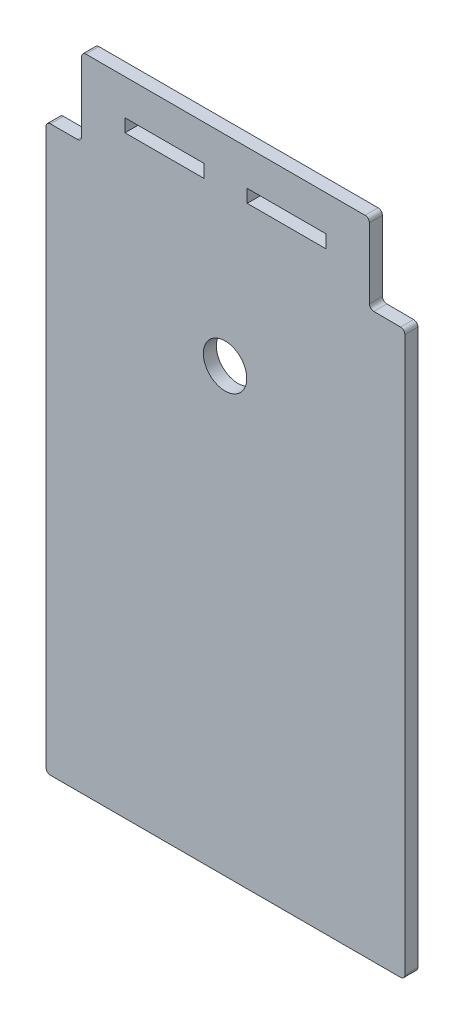
from build123d import *

# Parameters (mm, degrees)
MODEL_R                 = 5
MODEL_W                 = 18.163611367
MODEL_H                 = 3
MODEL_W_2               = 18.163611368
SALIENTE_EXTRUIR1_DEPTH = 3


with BuildPart() as part:
    # Model → Saliente-Extruir1 (new body)
    with BuildSketch(Plane.XY):
        with BuildLine():
            Line((95.99768192, -24.017865973), (95.99768192, 103.764725177))
            ThreePointArc((95.99768192, 103.764725177), (95.708514347, 104.473363697), (95.002958892, 104.769974448))
            Line((95.002958892, 104.769974448), (88.830267122, 104.802462525))
            ThreePointArc((88.830267122, 104.802462525), (88.124711667, 105.099073276), (87.835544094, 105.807711796))
            Line((87.835544094, 105.807711796), (87.824904655, 121.982134027))
            ThreePointArc((87.824904655, 121.982134027), (87.532011436, 122.689240808), (86.824904655, 122.982134027))
            Line((86.824904655, 122.982134027), (22.49768192, 122.982134027))
            ThreePointArc((22.49768192, 122.982134027), (21.790575139, 122.689240808), (21.49768192, 121.982134027))
            Line((21.49768192, 121.982134027), (21.49768192, 105.982134027))
            ThreePointArc((21.49768192, 105.982134027), (21.204788701, 105.275027246), (20.49768192, 104.982134027))
            Line((20.49768192, 104.982134027), (14.324904655, 104.982134027))
            ThreePointArc((14.324904655, 104.982134027), (13.617797874, 104.689240808), (13.324904655, 103.982134027))
            Line((13.324904655, 103.982134027), (13.324904655, 59.982134027))
            Line((13.324904655, 59.982134027), (13.324904655, 53.982134027))
            Line((13.324904655, 53.982134027), (13.324904655, 21.297944303))
            Line((13.324904655, 21.297944303), (13.324904655, -24.017865973))
            ThreePointArc((13.324904655, -24.017865973), (13.617797874, -24.724972754), (14.324904655, -25.017865973))
            Line((14.324904655, -25.017865973), (94.99768192, -25.017865973))
            ThreePointArc((94.99768192, -25.017865973), (95.704788701, -24.724972754), (95.99768192, -24.017865973))
        make_face()
        with Locations((54.561293288, 76.782134027)):
            Circle(MODEL_R, mode=Mode.SUBTRACT)
        with Locations((68.743098972, 113.282134027)):
            Rectangle(MODEL_W, MODEL_H, mode=Mode.SUBTRACT)
        with Locations((40.579487604, 113.282134027)):
            Rectangle(MODEL_W_2, MODEL_H, mode=Mode.SUBTRACT)
    extrude(amount=SALIENTE_EXTRUIR1_DEPTH)


solid = part.part
